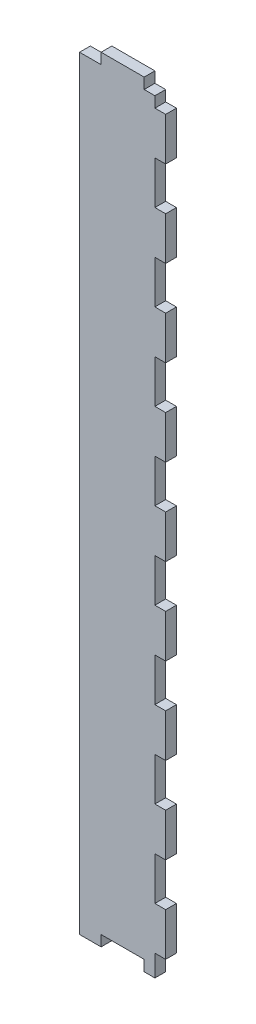
from build123d import *

# Parameters (mm, degrees)
SKETCH1_W          = 25.4
SKETCH1_H          = 228.6
EXTRUDE1_DEPTH     = 3.175
SKETCH3_W          = 3.175
SKETCH3_H          = 6.35
CUT_EXTRUDE1_DEPTH = 3.175
LPATTERN1_COUNT    = 2
LPATTERN1_PITCH    = 222.25
SKETCH4_W          = 3.175
SKETCH4_H          = 12.7
CUT_EXTRUDE2_DEPTH = 3.175
LPATTERN2_COUNT    = 8
LPATTERN2_PITCH    = 25.4
SKETCH5_W          = 12.7
SKETCH5_H          = 3.175
CUT_EXTRUDE3_DEPTH = 3.175
SKETCH6_W          = 6.35
SKETCH6_H          = 3.175
CUT_EXTRUDE4_DEPTH = 3.175
LPATTERN3_COUNT    = 2
LPATTERN3_PITCH    = 19.05


with BuildPart() as part:
    # Sketch1 → Extrude1 (new body)
    with BuildSketch(Plane.XY):
        with Locations((12.7, 114.3)):
            Rectangle(SKETCH1_W, SKETCH1_H)
    extrude(amount=EXTRUDE1_DEPTH)

    # Sketch3 → Cut-Extrude1 (cut)
    with BuildSketch(Plane.XY.offset(3.175)):
        with Locations((23.8125, 225.425)):
            Rectangle(SKETCH3_W, SKETCH3_H)
    cut_extrude1 = extrude(amount=-CUT_EXTRUDE1_DEPTH, mode=Mode.SUBTRACT)

    # LPattern1: Cut-Extrude1 ×2
    with Locations(*[(0, -i * LPATTERN1_PITCH, 0) for i in range(1, LPATTERN1_COUNT)]):
        add(cut_extrude1, mode=Mode.SUBTRACT)

    # Sketch4 → Cut-Extrude2 (cut)
    with BuildSketch(Plane.XY.offset(3.175)):
        with Locations((23.8125, 203.2)):
            Rectangle(SKETCH4_W, SKETCH4_H)
    cut_extrude2 = extrude(amount=-CUT_EXTRUDE2_DEPTH, mode=Mode.SUBTRACT)

    # LPattern2: Cut-Extrude2 ×8
    with Locations(*[(0, -i * LPATTERN2_PITCH, 0) for i in range(1, LPATTERN2_COUNT)]):
        add(cut_extrude2, mode=Mode.SUBTRACT)

    # Sketch5 → Cut-Extrude3 (cut)
    with BuildSketch(Plane.XY.offset(3.175)):
        with Locations((12.7, 1.5875)):
            Rectangle(SKETCH5_W, SKETCH5_H)
    extrude(amount=-CUT_EXTRUDE3_DEPTH, mode=Mode.SUBTRACT)

    # Sketch6 → Cut-Extrude4 (cut)
    with BuildSketch(Plane.XY.offset(3.175)):
        with Locations((3.175, 227.0125)):
            Rectangle(SKETCH6_W, SKETCH6_H)
    cut_extrude4 = extrude(amount=-CUT_EXTRUDE4_DEPTH, mode=Mode.SUBTRACT)

    # LPattern3: Cut-Extrude4 ×2
    with Locations(*[(i * LPATTERN3_PITCH, 0, 0) for i in range(1, LPATTERN3_COUNT)]):
        add(cut_extrude4, mode=Mode.SUBTRACT)


solid = part.part
